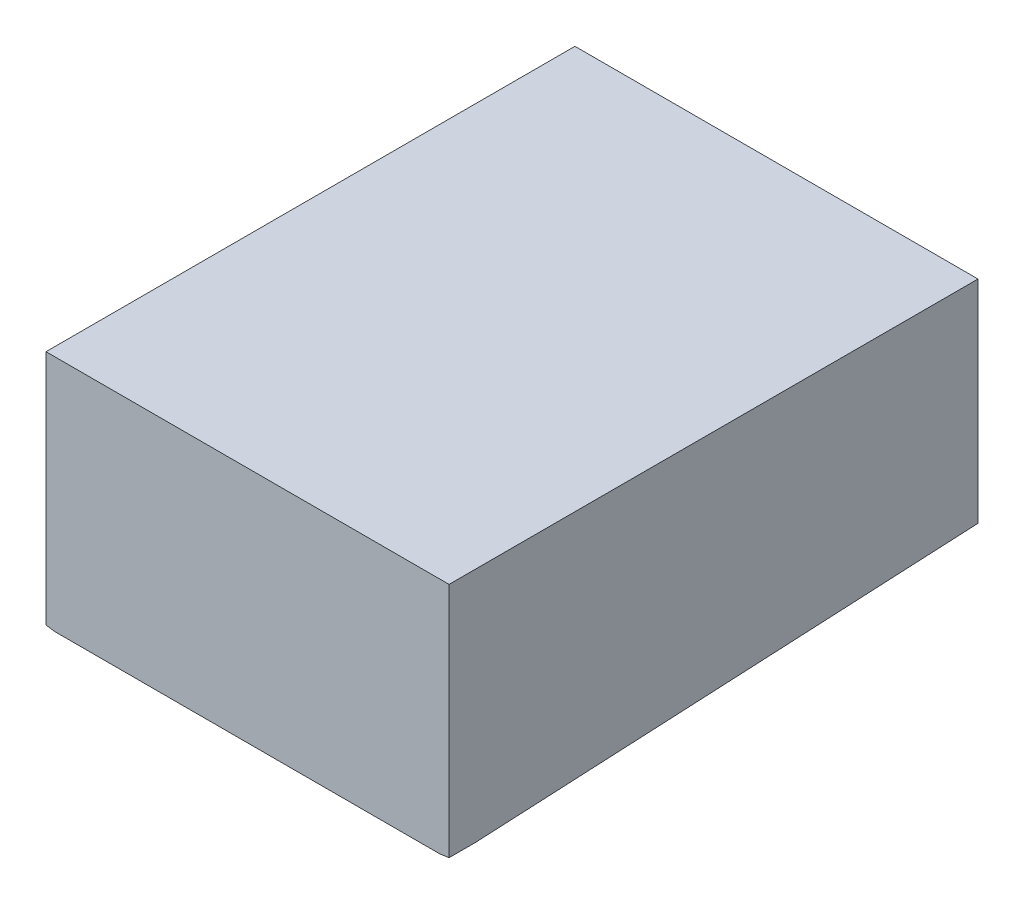
from build123d import *

# Parameters (mm, degrees)
BOSS_EXTRUDE1_DEPTH     = 200
CUT_EXTRUDE1_DEPTH      = 77.2000001
CUT_EXTRUDE1_DEPTH_BACK = 77.2000001


with BuildPart() as part:
    # Sketch17 → Boss-Extrude1 (new body)
    with BuildSketch(Plane.XY):
        with BuildLine():
            Line((-76.2, -15), (76.2, -15))
            Line((76.2, -15), (76.2, -104.498366301))
            add(Edge.make_bspline(
                [(-76.2, -104.498366301), (0, -115.791283906), (76.2, -104.498366301)],
                knots=[1.253188337, 1.253188337, 1.253188337, 1.888404317, 1.888404317, 1.888404317], degree=2, weights=[1, 0.949985148, 1]))
            Line((-76.2, -104.498366301), (-76.2, -15))
        make_face()
    extrude(amount=-BOSS_EXTRUDE1_DEPTH)

    # Sketch15 → Cut-Extrude1 (cut, two sides)
    with BuildSketch(Plane(origin=(0, 0, 0), x_dir=(0, 0, -1), z_dir=(1, 0, 0))) as cut_extrude1_sk:
        Polygon((0, -110), (200, -110), (200, -95), (0, -105), align=None)
    extrude(amount=CUT_EXTRUDE1_DEPTH, mode=Mode.SUBTRACT)
    extrude(cut_extrude1_sk.sketch, amount=-CUT_EXTRUDE1_DEPTH_BACK, mode=Mode.SUBTRACT)


solid = part.part
